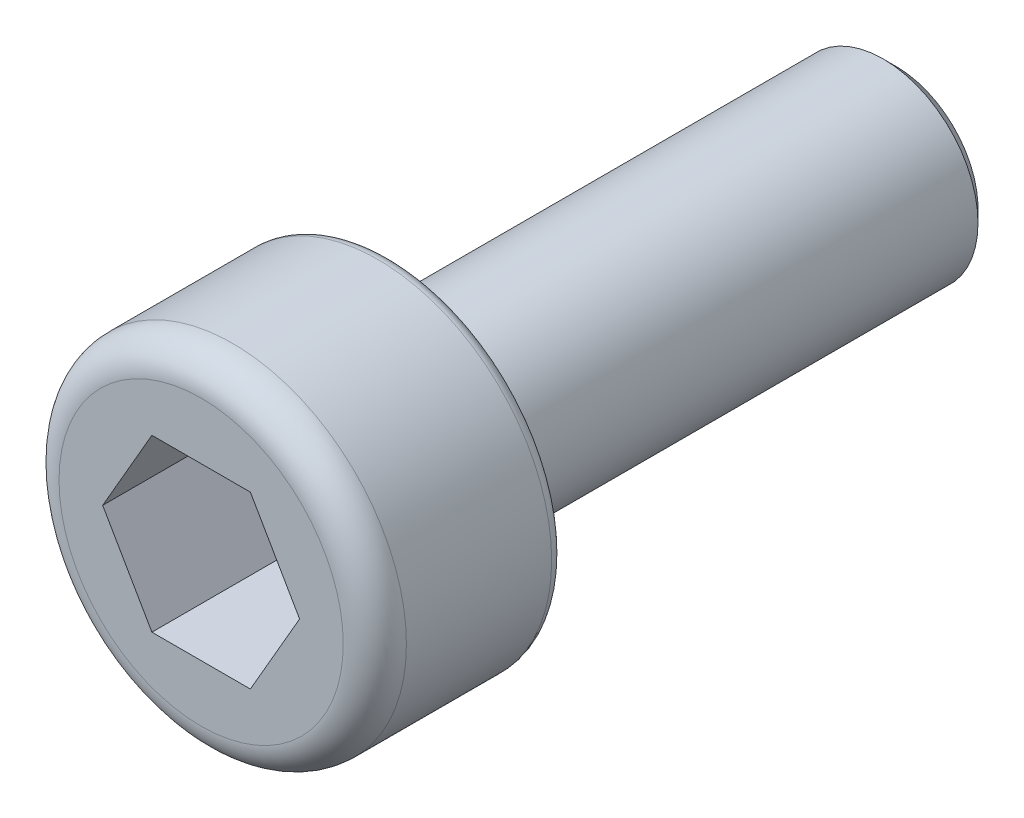
from build123d import *

# Parameters (mm, degrees)
SKETCH_1_R          = 2.75
EXTRUDE_1_DEPTH     = 3
FILLET_1_R          = 0.5
CUT_EXTRUDE_1_DEPTH = 2
SKETCH_3_R          = 1.5
EXTRUDE_2_DEPTH     = 8
CHAMFER_1_SIZE      = 0.2
FILLET_2_R          = 0.2


with BuildPart() as part:
    # 草图1 → 凸台-拉伸1 (new body)
    with BuildSketch(Plane.XY):
        Circle(SKETCH_1_R)
    extrude(amount=EXTRUDE_1_DEPTH)

    # 圆角1
    fillet_1_edges = [part.edges().sort_by_distance(p)[0] for p in [
        (-2.75, 0, 3),
    ]]
    fillet(fillet_1_edges, radius=FILLET_1_R)

    # 草图2 → 切除-拉伸1 (cut)
    with BuildSketch(Plane.XY.offset(3)):
        Polygon((1.558845727, 0), (0.779422863, 1.35), (-0.779422863, 1.35), (-1.558845727, 0), (-0.779422863, -1.35), (0.779422863, -1.35), align=None)
    extrude(amount=-CUT_EXTRUDE_1_DEPTH, mode=Mode.SUBTRACT)

    # 草图3 → 凸台-拉伸2 (add)
    with BuildSketch(Plane(origin=(0, 0, 0), x_dir=(-1, 0, 0), z_dir=(0, 0, -1))):
        Circle(SKETCH_3_R)
    extrude(amount=EXTRUDE_2_DEPTH)

    # 倒角1
    chamfer_1_edges = [part.edges().sort_by_distance(p)[0] for p in [
        (1.5, 0, -8),
    ]]
    chamfer(chamfer_1_edges, length=CHAMFER_1_SIZE)

    # 圆角2
    fillet_2_edges = [part.edges().sort_by_distance(p)[0] for p in [
        (-2.75, 0, 0),
    ]]
    fillet(fillet_2_edges, radius=FILLET_2_R)


solid = part.part
